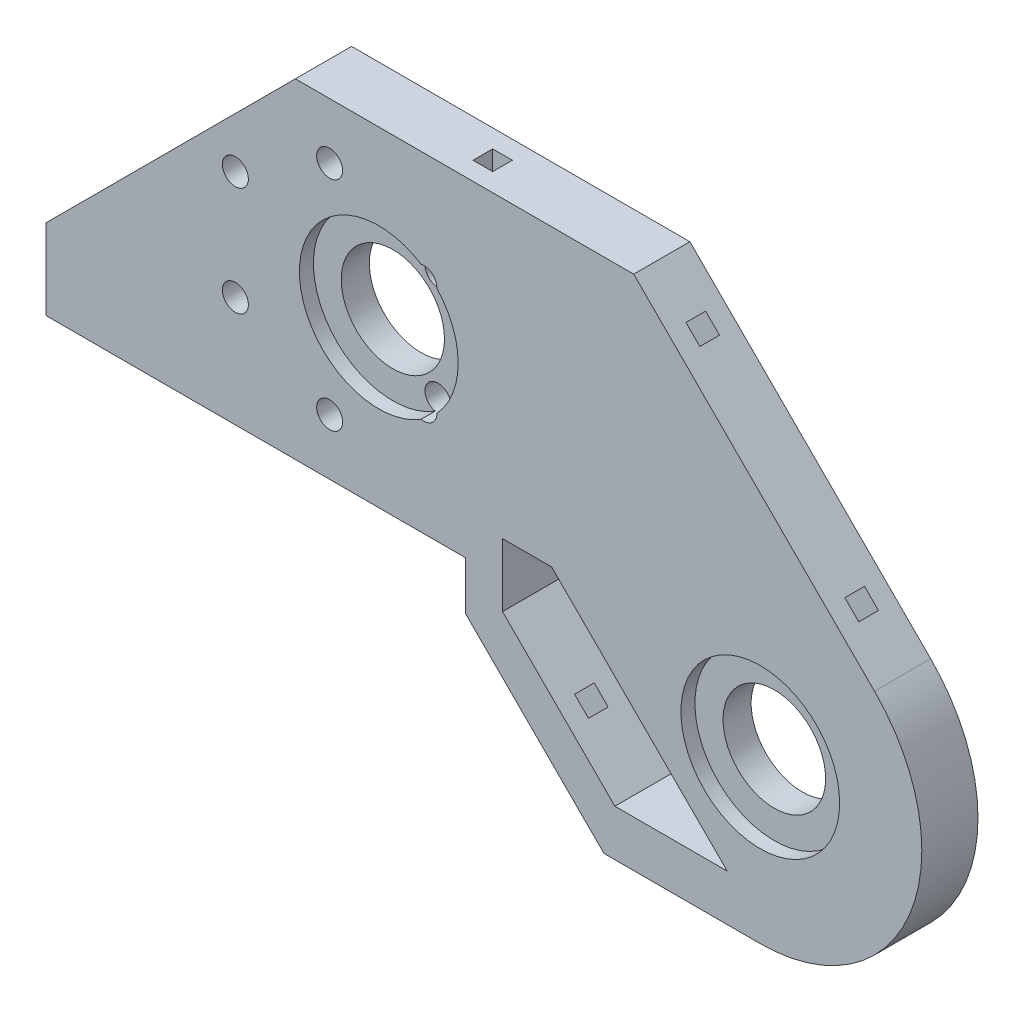
from build123d import *

# Parameters (mm, degrees)
MODEL_R                  = 7.35
MODEL_R_2                = 7.3
MODEL_R_3                = 1.85
RESSALTO_EXTRUS_O1_DEPTH = 8
ESBO_O3_R                = 11.3
CORTE_EXTRUS_O1_DEPTH    = 2
ESBO_O4_R                = 11.3
CORTE_EXTRUS_O2_DEPTH    = 2
ESBO_O2_R                = 3.3
CORTE_EXTRUS_O4_DEPTH    = 2
ESBO_O7_W                = 2.8
ESBO_O7_H                = 2.8
CORTE_EXTRUS_O6_DEPTH    = 6
ESBO_O8_W                = 2.8
ESBO_O8_H                = 2.8
CORTE_EXTRUS_O7_DEPTH    = 6
ESBO_O10_W               = 2.8
ESBO_O10_H               = 2.8
CORTE_EXTRUS_O9_DEPTH    = 6
RESSALTO_EXTRUS_O3_DEPTH = 8
ESBO_O6_R                = 1.5
CORTE_EXTRUS_O5_DEPTH    = 10
ESBO_O15_R               = 11.3
RESSALTO_EXTRUS_O4_DEPTH = 8


with BuildPart() as part:
    # Model → Ressalto-extrusão1 (new body)
    with BuildSketch(Plane.XY):
        with BuildLine():
            Line((0, 0), (39, 0))
            Line((39, 0), (39.7, 0))
            Line((39.7, 0), (39.7, -6.854833996))
            Line((39.7, -6.854833996), (52.445166004, -19.6))
            Line((52.445166004, -19.6), (59.445166004, -26.6))
            Line((59.445166004, -26.6), (81.699998871, -26.6))
            ThreePointArc((81.699998871, -26.6), (102.949229032, -12.401719466), (97.963455967, 12.663455967))
            Line((97.963455967, 12.663455967), (63.677897161, 46.949014774))
            Line((63.677897161, 46.949014774), (50.111140335, 46.949014774))
            Line((50.111140335, 46.949014774), (15.50707852, 46.949014774))
            Line((15.50707852, 46.949014774), (0, 31.441936254))
            Line((0, 31.441936254), (0, 0))
        make_face()
        with Locations((59.072583002, 19.027416998)):
            Circle(MODEL_R, mode=Mode.SUBTRACT)
        with Locations((81.7, -3.6)):
            Circle(MODEL_R_2, mode=Mode.SUBTRACT)
        with Locations((6.960594046, 15.730973227)):
            Circle(MODEL_R_3, mode=Mode.SUBTRACT)
        with Locations((6.960594046, 31.230973227)):
            Circle(MODEL_R_3, mode=Mode.SUBTRACT)
        with Locations((20.383987804, 38.980973227)):
            Circle(MODEL_R_3, mode=Mode.SUBTRACT)
        with Locations((33.807381563, 31.230973227)):
            Circle(MODEL_R_3, mode=Mode.SUBTRACT)
        with Locations((33.807381563, 15.730973227)):
            Circle(MODEL_R_3, mode=Mode.SUBTRACT)
        with Locations((20.383987804, 7.980973227)):
            Circle(MODEL_R_3, mode=Mode.SUBTRACT)
        with Locations((27.383987804, 23.480973227)):
            Circle(MODEL_R, mode=Mode.SUBTRACT)
        Polygon((72, -15), (52, 5), (45, 5), (45, -4), (61, -20), (77, -20), align=None, mode=Mode.SUBTRACT)
    extrude(amount=RESSALTO_EXTRUS_O1_DEPTH)

    # Esboço3 → Corte-extrusão1 (cut)
    with BuildSketch(Plane.XY):
        with Locations((81.7, -3.6)):
            Circle(ESBO_O3_R)
        with Locations((59.0726, 19.0274)):
            Circle(ESBO_O3_R)
        with Locations((27.384004802, 23.480956229)):
            Circle(ESBO_O3_R)
    extrude(amount=CORTE_EXTRUS_O1_DEPTH, mode=Mode.SUBTRACT)

    # Esboço4 → Corte-extrusão2 (cut)
    with BuildSketch(Plane.XY.offset(8)):
        with Locations((81.7, -3.6)):
            Circle(ESBO_O4_R)
        with Locations((59.0726, 19.0274)):
            Circle(ESBO_O4_R)
        with Locations((27.384004802, 23.480956229)):
            Circle(ESBO_O4_R)
    extrude(amount=-CORTE_EXTRUS_O2_DEPTH, mode=Mode.SUBTRACT)

    # Esboço2 → Corte-extrusão4 (cut)
    with BuildSketch(Plane.XY):
        with Locations((6.960594802, 15.730956229)):
            Circle(ESBO_O2_R)
        with Locations((6.960594802, 31.230956229)):
            Circle(ESBO_O2_R)
        with Locations((33.807404802, 15.730956229)):
            Circle(ESBO_O2_R)
        with Locations((20.384004802, 38.980956229)):
            Circle(ESBO_O2_R)
        with Locations((33.807404802, 31.230956229)):
            Circle(ESBO_O2_R)
        with Locations((20.384004802, 7.980976229)):
            Circle(ESBO_O2_R)
    extrude(amount=CORTE_EXTRUS_O4_DEPTH, mode=Mode.SUBTRACT)

    # Esboço7 → Corte-extrusão6 (cut)
    with BuildSketch(Plane(origin=(55.313455967, 55.313455967, 0), x_dir=(0, 0, -1), z_dir=(0.707106781, 0.707106781, 0))):
        with Locations((-4, -52.072657306)):
            Rectangle(ESBO_O7_W, ESBO_O7_H)
        with Locations((-4, -20.072657306)):
            Rectangle(ESBO_O7_W, ESBO_O7_H)
    extrude(amount=-CORTE_EXTRUS_O6_DEPTH, mode=Mode.SUBTRACT)

    # Esboço8 → Corte-extrusão7 (cut)
    with BuildSketch(Plane(origin=(0, 46.949014774, 0), x_dir=(1, 0, 0), z_dir=(0, 1, 0))):
        with Locations((39.59248784, -4)):
            Rectangle(ESBO_O8_W, ESBO_O8_H)
    extrude(amount=-CORTE_EXTRUS_O7_DEPTH, mode=Mode.SUBTRACT)

    # Esboço10 → Corte-extrusão9 (cut)
    with BuildSketch(Plane(origin=(16.422583002, 16.422583002, 0), x_dir=(0, 0, 1), z_dir=(-0.707106781, -0.707106781, 0))):
        with Locations((4, -46.881179593)):
            Rectangle(ESBO_O10_W, ESBO_O10_H)
    extrude(amount=-CORTE_EXTRUS_O9_DEPTH, mode=Mode.SUBTRACT)

    # Esboço13 → Ressalto-extrusão3 (add)
    with BuildSketch(Plane.XY.offset(8)):
        Polygon((0, 31.441936254), (-20, 11.441936254), (-20, 0), (0, 0), align=None)
    extrude(amount=-RESSALTO_EXTRUS_O3_DEPTH)

    # Esboço6 → Corte-extrusão5 (cut)
    with BuildSketch(Plane.XZ):
        with Locations((4.7, 4)):
            Circle(ESBO_O6_R)
        with Locations((23.7, 4)):
            Circle(ESBO_O6_R)
        with Locations((-14.3, 4)):
            Circle(ESBO_O6_R)
    extrude(amount=-CORTE_EXTRUS_O5_DEPTH, mode=Mode.SUBTRACT)

    # Esboço15 → Ressalto-extrusão4 (add)
    with BuildSketch(Plane.XY.offset(8)):
        with Locations((59.0726, 19.0274)):
            Circle(ESBO_O15_R)
    extrude(amount=-RESSALTO_EXTRUS_O4_DEPTH)


solid = part.part
